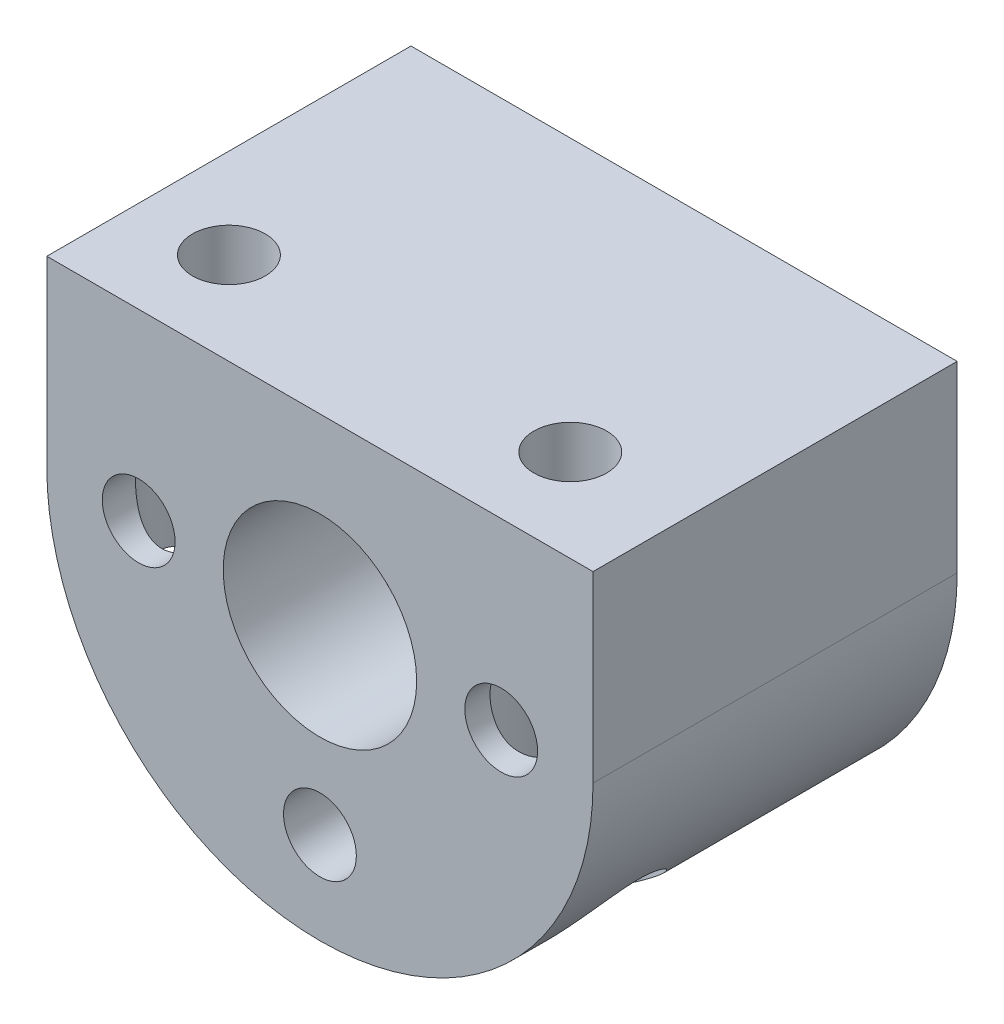
from build123d import *

# Parameters (mm, degrees)
RESSALTO_EXTRUS_O1_DEPTH                = 10
RESSALTO_EXTRUS_O1_DEPTH_BACK           = 6
ESBO_O2_R                               = 5.25
CORTE_EXTRUS_O1_DEPTH                   = 16
CORTE_EXTRUS_O1_DEPTH_BACK              = 31.8
M3_CLEARANCE_HOLE5_D                    = 3.2
CBORE_FOR_M5_HEX_HEAD_BOLT1_D           = 3.2
CBORE_FOR_M5_HEX_HEAD_BOLT1_CBORE_D     = 6
CBORE_FOR_M5_HEX_HEAD_BOLT1_CBORE_DEPTH = 16.5
SKETCH11_W                              = 24
SKETCH11_H                              = 16
SKETCH11_R                              = 1.6
BOSS_EXTRUDE3_DEPTH                     = 1
SKETCH12_R                              = 5.25
SKETCH12_R_2                            = 4.25
BOSS_EXTRUDE5_DEPTH                     = 6
CHAMFER1_SIZE                           = 0.3
SKETCH13_R                              = 3
CUT_EXTRUDE1_DEPTH                      = 43.8


with BuildPart() as part:
    # Esboço1 → Ressalto-extrusão1 (new body, two sides)
    with BuildSketch(Plane.XY) as ressalto_extrus_o1_sk:
        with BuildLine():
            Line((115.646593224, -302.7659332), (115.646593224, -295.7159332))
            Line((115.646593224, -295.7159332), (91.646593224, -295.7159332))
            Line((91.646593224, -295.7159332), (91.646593224, -302.7659332))
            ThreePointArc((91.646593224, -302.7659332), (103.646593224, -314.7659332), (115.646593224, -302.7659332))
        make_face()
    extrude(amount=RESSALTO_EXTRUS_O1_DEPTH)
    extrude(ressalto_extrus_o1_sk.sketch, amount=-RESSALTO_EXTRUS_O1_DEPTH_BACK)

    # Esboço2 → Corte-extrusão1 (cut, two sides)
    with BuildSketch(Plane.XY.offset(10)) as corte_extrus_o1_sk:
        with Locations((103.646593224, -302.7659332)):
            Circle(ESBO_O2_R)
    extrude(amount=CORTE_EXTRUS_O1_DEPTH, mode=Mode.SUBTRACT)
    extrude(corte_extrus_o1_sk.sketch, amount=-CORTE_EXTRUS_O1_DEPTH_BACK, mode=Mode.SUBTRACT)

    # M3 Clearance Hole5 (through all)
    with Locations(Plane.XY.offset(10)):
        with Locations((95.681870132, -302.765933199), (103.646593224, -310.730656291), (111.611316315, -302.765933199)):
            Hole(M3_CLEARANCE_HOLE5_D / 2)

    # CBORE for M5 Hex Head Bolt1 (through all)
    with Locations(Plane(origin=(0, -314.7159332, 0), x_dir=(-1, 0, 0), z_dir=(0, -1, 0))):
        with Locations((-95.596593224, -5.949346208), (-110.596593224, -5.949346208)):
            CounterBoreHole(CBORE_FOR_M5_HEX_HEAD_BOLT1_D / 2, CBORE_FOR_M5_HEX_HEAD_BOLT1_CBORE_D / 2, CBORE_FOR_M5_HEX_HEAD_BOLT1_CBORE_DEPTH)

    # Sketch11 → Boss-Extrude3 (add)
    with BuildSketch(Plane(origin=(0, -295.7159332, 0), x_dir=(1, 0, 0), z_dir=(0, 1, 0))):
        with Locations((103.646593224, -2)):
            Rectangle(SKETCH11_W, SKETCH11_H)
        with Locations((95.596593224, -5.949346208)):
            Circle(SKETCH11_R, mode=Mode.SUBTRACT)
        with Locations((110.596593224, -5.949346208)):
            Circle(SKETCH11_R, mode=Mode.SUBTRACT)
    extrude(amount=BOSS_EXTRUDE3_DEPTH)

    # Sketch12 → Boss-Extrude5 (add)
    with BuildSketch(Plane.XY.offset(10)):
        with Locations((103.646593224, -302.7659332)):
            Circle(SKETCH12_R)
        with Locations((103.646593224, -302.7659332)):
            Circle(SKETCH12_R_2, mode=Mode.SUBTRACT)
    extrude(amount=-BOSS_EXTRUDE5_DEPTH)

    # Chamfer1
    chamfer1_edges = [part.edges().sort_by_distance(p)[0] for p in [
        (98.396593224, -302.7659332, -6),
    ]]
    chamfer(chamfer1_edges, length=CHAMFER1_SIZE)

    # Sketch13 → Cut-Extrude1 (cut)
    with BuildSketch(Plane.XZ.offset(298.2159332)):
        with Locations((95.596593224, 5.949346208)):
            Circle(SKETCH13_R)
        with Locations((110.596593224, 5.949346208)):
            Circle(SKETCH13_R)
    extrude(amount=CUT_EXTRUDE1_DEPTH, mode=Mode.SUBTRACT)


solid = part.part
